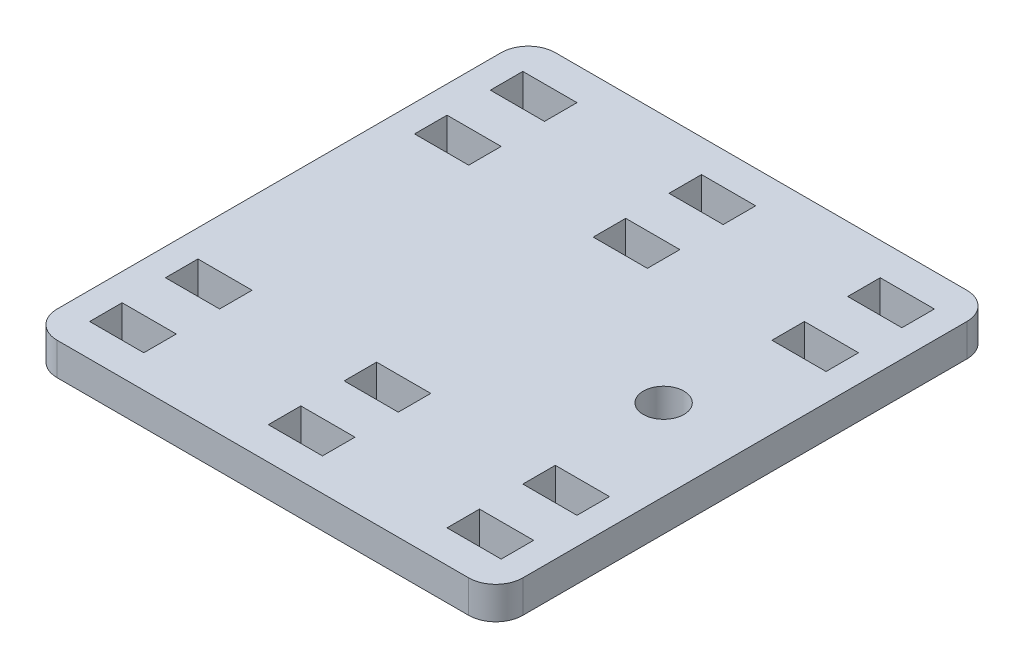
from build123d import *

# Parameters (mm, degrees)
SKETCH1_W                  = 86
SKETCH1_H                  = 92
BOSS_EXTRUDE1_DEPTH        = 6
F_7_5_7_5_DIAMETER_HOLE1_D = 7.5
SKETCH6_W                  = 10
SKETCH6_H                  = 6
CUT_EXTRUDE1_DEPTH         = 4
SKETCH61_W                 = 10
SKETCH61_H                 = 6
CUT_EXTRUDE11_DEPTH        = 4
SKETCH62_W                 = 10
SKETCH62_H                 = 6
CUT_EXTRUDE12_DEPTH        = 4
SKETCH64_W                 = 10
SKETCH64_H                 = 6
CUT_EXTRUDE14_DEPTH        = 4
SKETCH65_W                 = 10
SKETCH65_H                 = 6
CUT_EXTRUDE15_DEPTH        = 4
SKETCH66_W                 = 10
SKETCH66_H                 = 6
CUT_EXTRUDE16_DEPTH        = 4
FILLET1_R                  = 5


with BuildPart() as part:
    # Sketch1 → Boss-Extrude1 (new body)
    with BuildSketch(Plane(origin=(0, 0, 0), x_dir=(1, 0, 0), z_dir=(0, 1, 0))):
        with Locations((43, 46)):
            Rectangle(SKETCH1_W, SKETCH1_H)
    extrude(amount=BOSS_EXTRUDE1_DEPTH)

    # Ø7.5 (7.5) Diameter Hole1 (through all)
    with Locations(Plane(origin=(0, 6, 0), x_dir=(1, 0, 0), z_dir=(0, 1, 0))):
        with Locations((71, 46)):
            Hole(F_7_5_7_5_DIAMETER_HOLE1_D / 2)

    # Sketch6 → Cut-Extrude1 (cut, symmetric)
    with BuildSketch(Plane(origin=(9.232221392, 3, 35), x_dir=(1, 0, 0), z_dir=(0, -1, 0))):
        with Locations((0.767778608, -44)):
            Rectangle(SKETCH6_W, SKETCH6_H)
    cut_extrude1 = extrude(amount=CUT_EXTRUDE1_DEPTH, both=True, mode=Mode.SUBTRACT)

    # Sketch61 → Cut-Extrude11 (cut, symmetric)
    with BuildSketch(Plane(origin=(42.232221392, 3, 35), x_dir=(1, 0, 0), z_dir=(0, -1, 0))):
        with Locations((0.767778608, -44)):
            Rectangle(SKETCH61_W, SKETCH61_H)
    cut_extrude11 = extrude(amount=CUT_EXTRUDE11_DEPTH, both=True, mode=Mode.SUBTRACT)

    # Sketch62 → Cut-Extrude12 (cut, symmetric)
    with BuildSketch(Plane(origin=(75.232221392, 3, 35), x_dir=(1, 0, 0), z_dir=(0, -1, 0))):
        with Locations((0.767778608, -44)):
            Rectangle(SKETCH62_W, SKETCH62_H)
    cut_extrude12 = extrude(amount=CUT_EXTRUDE12_DEPTH, both=True, mode=Mode.SUBTRACT)

    # Sketch64 → Cut-Extrude14 (cut, symmetric)
    with BuildSketch(Plane(origin=(9.232221392, 3, 21), x_dir=(1, 0, 0), z_dir=(0, -1, 0))):
        with Locations((0.767778608, -44)):
            Rectangle(SKETCH64_W, SKETCH64_H)
    cut_extrude14 = extrude(amount=CUT_EXTRUDE14_DEPTH, both=True, mode=Mode.SUBTRACT)

    # Sketch65 → Cut-Extrude15 (cut, symmetric)
    with BuildSketch(Plane(origin=(42.232221392, 3, 21), x_dir=(1, 0, 0), z_dir=(0, -1, 0))):
        with Locations((0.767778608, -44)):
            Rectangle(SKETCH65_W, SKETCH65_H)
    cut_extrude15 = extrude(amount=CUT_EXTRUDE15_DEPTH, both=True, mode=Mode.SUBTRACT)

    # Sketch66 → Cut-Extrude16 (cut, symmetric)
    with BuildSketch(Plane(origin=(75.232221392, 3, 21), x_dir=(1, 0, 0), z_dir=(0, -1, 0))):
        with Locations((0.767778608, -44)):
            Rectangle(SKETCH66_W, SKETCH66_H)
    cut_extrude16 = extrude(amount=CUT_EXTRUDE16_DEPTH, both=True, mode=Mode.SUBTRACT)

    # Mirror1: Cut-Extrude1, Cut-Extrude11, Cut-Extrude12, Cut-Extrude14, Cut-Extrude15, Cut-Extrude16 across plane
    add(cut_extrude1.mirror(Plane.XY.offset(-46)), mode=Mode.SUBTRACT)
    add(cut_extrude11.mirror(Plane.XY.offset(-46)), mode=Mode.SUBTRACT)
    add(cut_extrude12.mirror(Plane.XY.offset(-46)), mode=Mode.SUBTRACT)
    add(cut_extrude14.mirror(Plane.XY.offset(-46)), mode=Mode.SUBTRACT)
    add(cut_extrude15.mirror(Plane.XY.offset(-46)), mode=Mode.SUBTRACT)
    add(cut_extrude16.mirror(Plane.XY.offset(-46)), mode=Mode.SUBTRACT)

    # Fillet1
    fillet1_edges = [part.edges().sort_by_distance(p)[0] for p in [
        (0, 3, -92),
        (86, 3, -92),
        (86, 3, 0),
        (0, 3, 0),
    ]]
    fillet(fillet1_edges, radius=FILLET1_R)


solid = part.part
